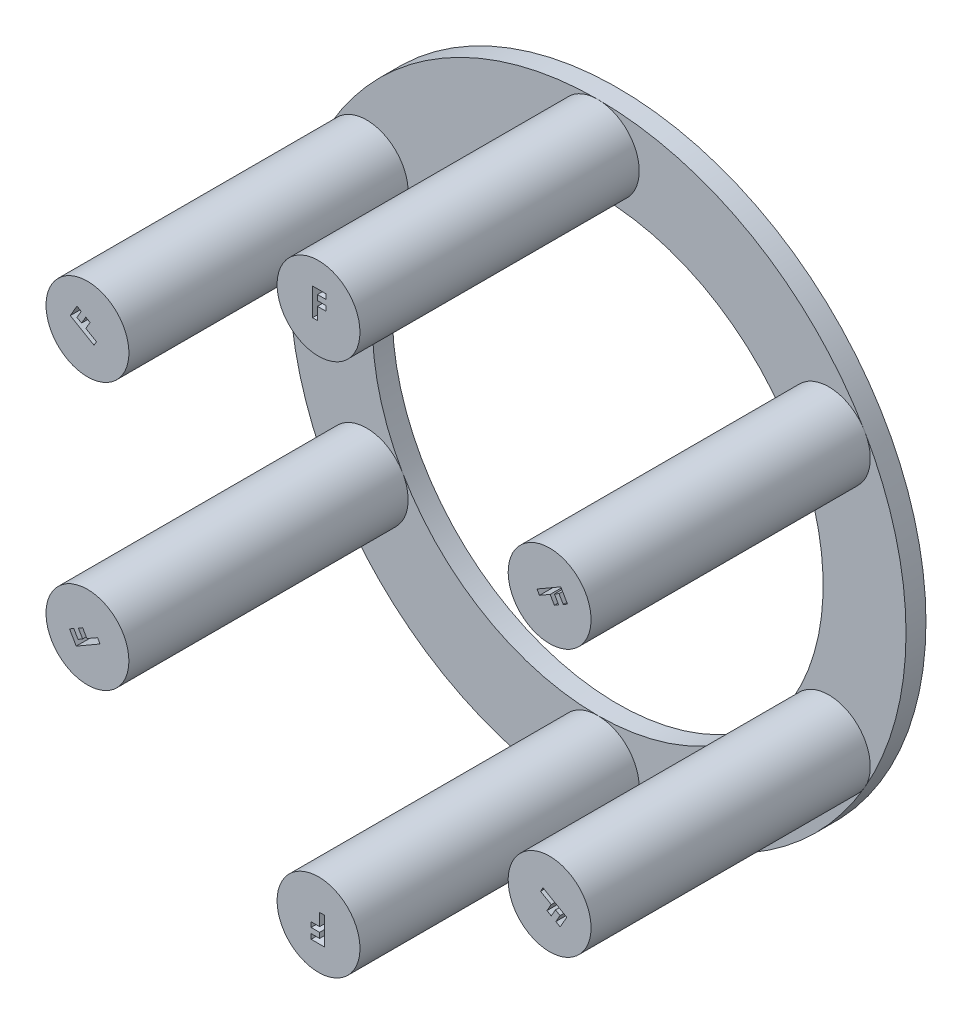
from build123d import *

# Parameters (mm, degrees)
SKETCH2_R           = 39.2557
SKETCH2_R_2         = 28.702
BOSS_EXTRUDE1_DEPTH = 2.54
SKETCH3_R           = 5.27685
BOSS_EXTRUDE2_DEPTH = 35.56
CUT_EXTRUDE1_DEPTH  = 2.54
CIRPATTERN1_COUNT   = 6


with BuildPart() as part:
    # Sketch2 → Boss-Extrude1 (new body)
    with BuildSketch(Plane.XY):
        Circle(SKETCH2_R)
        Circle(SKETCH2_R_2, mode=Mode.SUBTRACT)
    extrude(amount=BOSS_EXTRUDE1_DEPTH)

    # Sketch3 → Boss-Extrude2 (add)
    with BuildSketch(Plane.XY.offset(2.54)):
        with Locations(Location((0, 33.97885, 0), (0, 0, 269.999675818))):
            Circle(SKETCH3_R)
    boss_extrude2 = extrude(amount=BOSS_EXTRUDE2_DEPTH)

    # Sketch4 → Cut-Extrude1 (cut)
    with BuildSketch(Plane.XY.offset(38.1)):
        Polygon((-0.762820513, 36.068090357), (0.942307692, 36.068090357), (0.942307692, 35.439885228), (-0.134615385, 35.439885228), (-0.134615385, 34.766808305), (0.942307692, 34.766808305), (0.942307692, 34.138603177), (-0.134615385, 34.138603177), (-0.134615385, 32.568090357), (-0.762820513, 32.568090357), align=None)
    cut_extrude1 = extrude(amount=-CUT_EXTRUDE1_DEPTH, mode=Mode.SUBTRACT)

    # CirPattern1: Boss-Extrude2, Cut-Extrude1 ×6 about axis
    cirpattern1_axis = Axis((0, 0, 0), (0, 0, 1))
    add([boss_extrude2.rotate(cirpattern1_axis, i * 360 / CIRPATTERN1_COUNT) for i in range(1, CIRPATTERN1_COUNT)])
    add([cut_extrude1.rotate(cirpattern1_axis, i * 360 / CIRPATTERN1_COUNT) for i in range(1, CIRPATTERN1_COUNT)], mode=Mode.SUBTRACT)


solid = part.part
